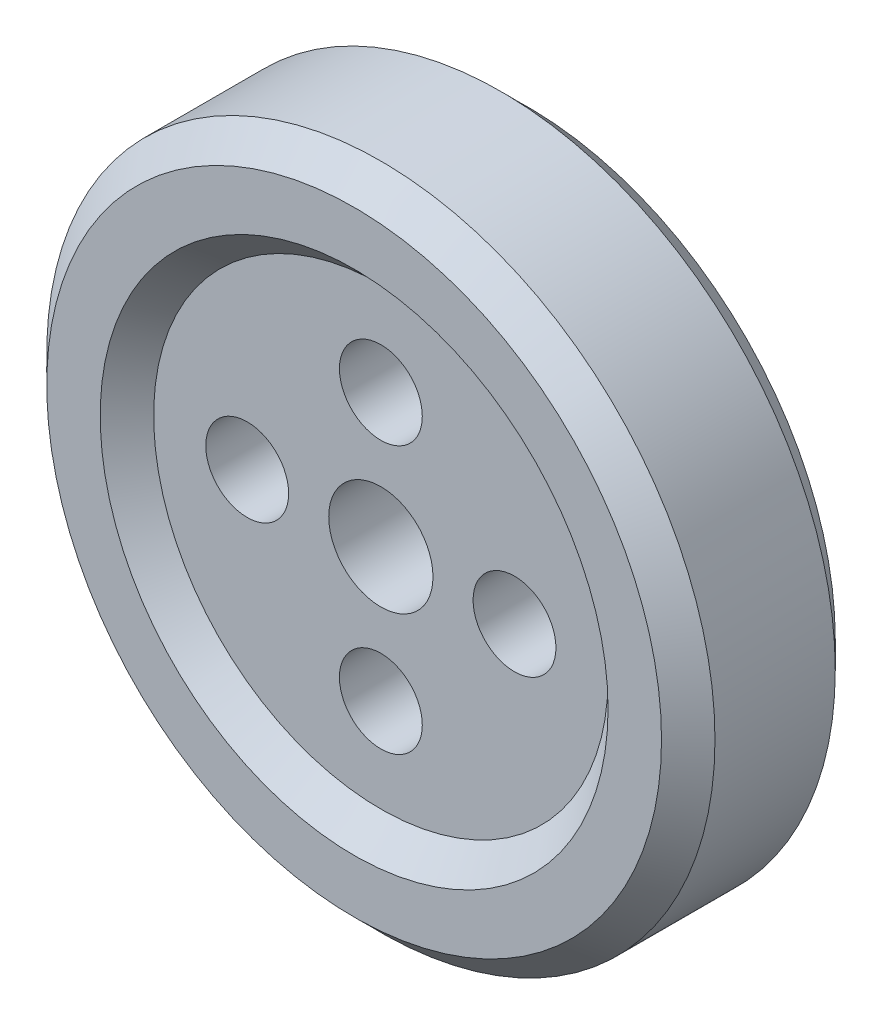
from build123d import *

# Parameters (mm, degrees)
SKETCH1_R           = 250
BOSS_EXTRUDE1_DEPTH = 65
CHAMFER1_SIZE       = 20
SKETCH2_R           = 190
CUT_EXTRUDE1_DEPTH  = 20
CUT_EXTRUDE1_TAPER  = 45
SKETCH3_R           = 190
CUT_EXTRUDE2_DEPTH  = 20
CUT_EXTRUDE2_TAPER  = 45
SKETCH4_R           = 31
SKETCH4_R_2         = 39
CUT_EXTRUDE3_DEPTH  = 111.0000001


with BuildPart() as part:
    # Sketch1 → Boss-Extrude1 (new body, symmetric)
    with BuildSketch(Plane.XY):
        Circle(SKETCH1_R)
    extrude(amount=BOSS_EXTRUDE1_DEPTH, both=True)

    # Chamfer1
    chamfer1_edges = [part.edges().sort_by_distance(p)[0] for p in [
        (-250, 0, -65),
        (-250, 0, 65),
    ]]
    chamfer(chamfer1_edges, length=CHAMFER1_SIZE)

    # Sketch2 → Cut-Extrude1 (cut)
    with BuildSketch(Plane.XY.offset(65)):
        Circle(SKETCH2_R)
    extrude(amount=-CUT_EXTRUDE1_DEPTH, taper=CUT_EXTRUDE1_TAPER, mode=Mode.SUBTRACT)

    # Sketch3 → Cut-Extrude2 (cut)
    with BuildSketch(Plane(origin=(0, 0, -65), x_dir=(-1, 0, 0), z_dir=(0, 0, -1))):
        Circle(SKETCH3_R)
    extrude(amount=-CUT_EXTRUDE2_DEPTH, taper=CUT_EXTRUDE2_TAPER, mode=Mode.SUBTRACT)

    # Sketch4 → Cut-Extrude3 (cut, through all)
    with BuildSketch(Plane(origin=(0, 0, -45), x_dir=(-1, 0, 0), z_dir=(0, 0, -1))):
        with Locations((0, 100)):
            Circle(SKETCH4_R)
        with Locations((-100, 0)):
            Circle(SKETCH4_R)
        with Locations((0, -100)):
            Circle(SKETCH4_R)
        with Locations((100, 0)):
            Circle(SKETCH4_R)
        Circle(SKETCH4_R_2)
    extrude(amount=-CUT_EXTRUDE3_DEPTH, mode=Mode.SUBTRACT)


solid = part.part
